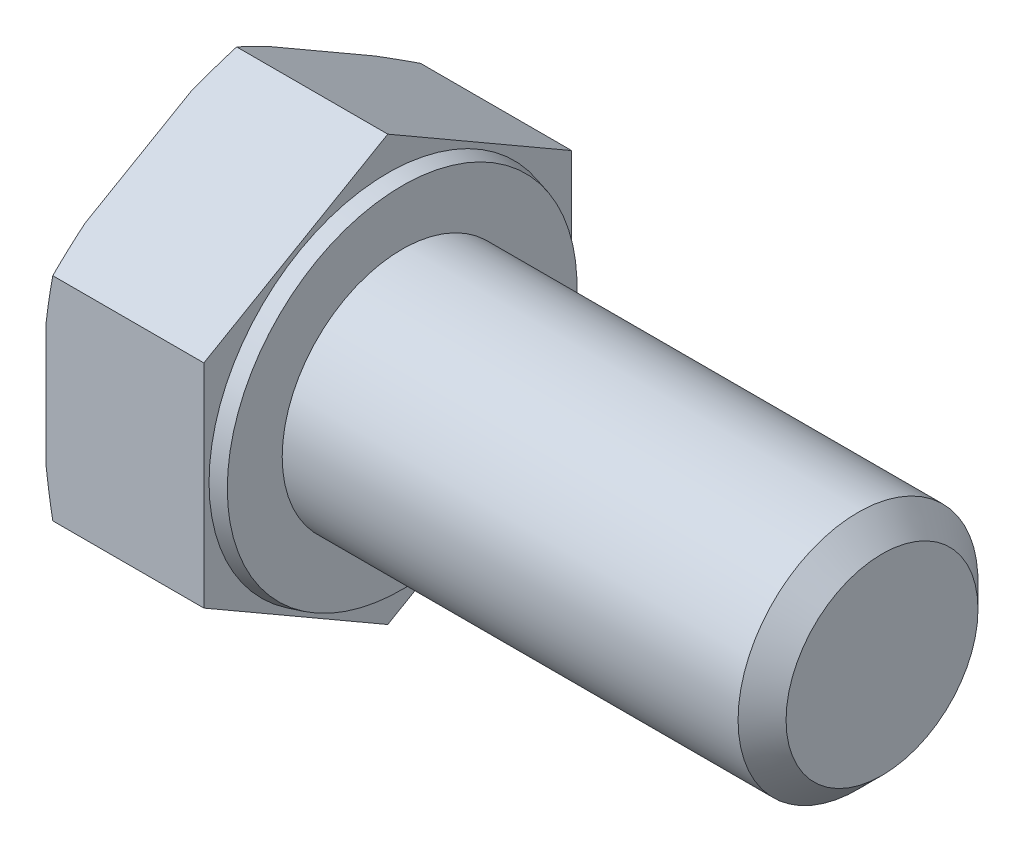
from build123d import *

# Parameters (mm, degrees)
SKETCH_2_OUTSIDE_W  = 27.09
SKETCH_2_OUTSIDE_H  = 27.09
CUT_EXTRUDE_1_DEPTH = 28.18
CHAMFER_1_SIZE      = 1


with BuildPart() as part:
    # Эскиз1 → Повернуть1 (revolve)
    with BuildSketch(Plane.XY):
        Polygon((-6.58, 0), (-6.58, 8.85), (0, 8.85), (0, 7.448974596), (0.6, 7.288205081), (0.6, 5), (20.6, 5), (20.6, 0), align=None)
    revolve(axis=Axis((-1000, 0, 0), (1, 0, 0)))

    # Эскиз2 outside → Вырез-Вытянуть1 (cut, through all)
    with BuildSketch(Plane.ZY.offset(6.58)):
        Rectangle(SKETCH_2_OUTSIDE_W, SKETCH_2_OUTSIDE_H)
        Polygon((0, -8.85), (7.664324823, -4.425), (7.664324823, 4.425), (0, 8.85), (-7.664324823, 4.425), (-7.664324823, -4.425), align=None, mode=Mode.SUBTRACT)
    extrude(amount=-CUT_EXTRUDE_1_DEPTH, mode=Mode.SUBTRACT)

    # Эскиз4 → Вырез-Повернуть1 (revolve, cut)
    with BuildSketch(Plane.XY):
        Polygon((-6.58, 8.075), (-6.297923068, 8.85), (-6.58, 8.85), align=None)
    revolve(axis=Axis((-1000, 0, 0), (1, 0, 0)), mode=Mode.SUBTRACT)

    # Фаска1
    chamfer_1_edges = [part.edges().sort_by_distance(p)[0] for p in [
        (20.6, -5, 0),
    ]]
    chamfer(chamfer_1_edges, length=CHAMFER_1_SIZE)


solid = part.part
